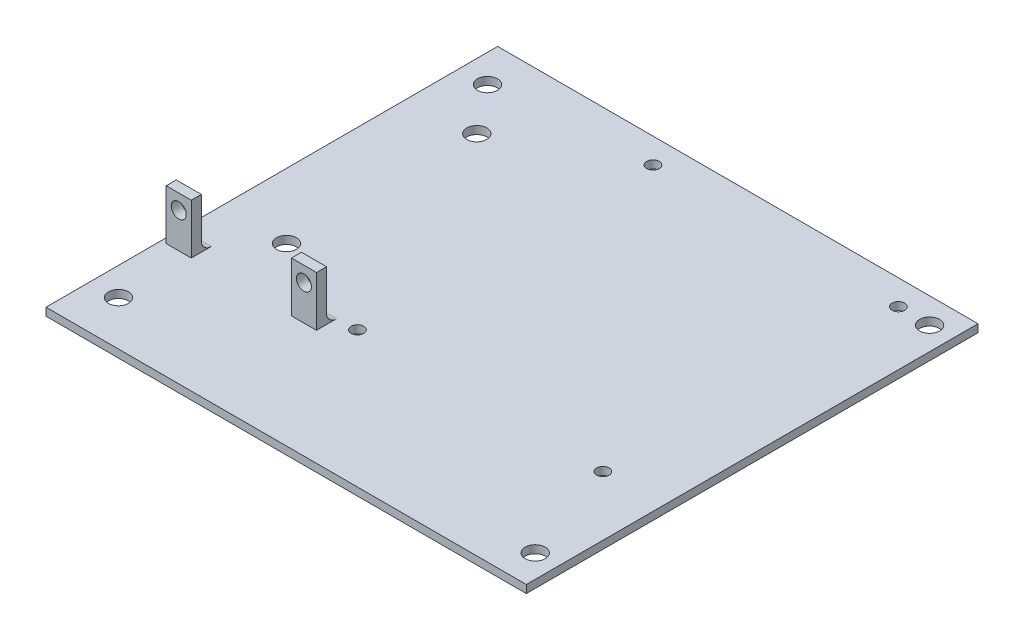
from build123d import *

# Parameters (mm, degrees)
SKETCH1_W               = 96.89
SKETCH1_H               = 90.17
PCB_DEPTH               = 1.57
SKETCH2_R               = 2
M3_MOUNTING_HOLES_DEPTH = 1.57
SKETCH5_W               = 0.5
SKETCH5_H               = 90.17
CUT_EXTRUDE1_DEPTH      = 2.57
SKETCH8_R               = 1.25
RPI_MOUNTING_HOLE_DEPTH = 10
SKETCH9_R               = 2
POWERADAPTERHOLES_DEPTH = 10
SKETCH10_W              = 5
SKETCH10_H              = 2
DSUB_HOLDER_DEPTH       = 10
FILLET2_R               = 2
DSUB_FIELDS_REACH       = 69.17
SKETCH11_R              = 1.5


with BuildPart() as part:
    # Sketch1 → PCB (new body)
    with BuildSketch(Plane(origin=(0, 0, 0), x_dir=(1, 0, 0), z_dir=(0, 1, 0))):
        with Locations((16.200949951, 63.633996534)):
            Rectangle(SKETCH1_W, SKETCH1_H)
    extrude(amount=PCB_DEPTH)

    # Sketch2 → M3 Mounting Holes (cut)
    with BuildSketch(Plane(origin=(0, 1.57, 0), x_dir=(1, 0, 0), z_dir=(0, 1, 0))):
        with Locations((59.565949951, 24.898996534)):
            Circle(SKETCH2_R)
        with Locations((-26.164050049, 27.438996534)):
            Circle(SKETCH2_R)
        with Locations((-26.164050049, 101.098996534)):
            Circle(SKETCH2_R)
        with Locations((59.565949951, 103.638996534)):
            Circle(SKETCH2_R)
    extrude(amount=-M3_MOUNTING_HOLES_DEPTH, mode=Mode.SUBTRACT)

    # Sketch5 → Cut-Extrude1 (cut, through all)
    with BuildSketch(Plane(origin=(0, 1.57, 0), x_dir=(1, 0, 0), z_dir=(0, 1, 0))):
        with Locations((-31.994050049, 63.633996534)):
            Rectangle(SKETCH5_W, SKETCH5_H)
        with Locations((64.395949951, 63.633996534)):
            Rectangle(SKETCH5_W, SKETCH5_H)
    extrude(amount=-CUT_EXTRUDE1_DEPTH, mode=Mode.SUBTRACT)

    # Sketch8 → RPi mounting hole (cut)
    with BuildSketch(Plane(origin=(0, 1.57, 0), x_dir=(1, 0, 0), z_dir=(0, 1, 0))):
        with Locations((3.255949951, 45.718996534)):
            Circle(SKETCH8_R)
        with Locations((52.255949951, 45.718996534)):
            Circle(SKETCH8_R)
        with Locations((4.255949951, 103.718996534)):
            Circle(SKETCH8_R)
        with Locations((53.255949951, 103.718996534)):
            Circle(SKETCH8_R)
    extrude(amount=-RPI_MOUNTING_HOLE_DEPTH, mode=Mode.SUBTRACT)

    # Sketch9 → PowerAdapterHoles (cut)
    with BuildSketch(Plane(origin=(0, 1.57, 0), x_dir=(1, 0, 0), z_dir=(0, 1, 0))):
        with Locations((-18.744050049, 91.548996534)):
            Circle(SKETCH9_R)
        with Locations((-18.744050049, 53.548996534)):
            Circle(SKETCH9_R)
    extrude(amount=-POWERADAPTERHOLES_DEPTH, mode=Mode.SUBTRACT)

    # Sketch10 → DSub Holder (add)
    with BuildSketch(Plane(origin=(0, 1.57, 0), x_dir=(1, 0, 0), z_dir=(0, 1, 0))):
        with Locations((-28.244050049, 42.548996534)):
            Rectangle(SKETCH10_W, SKETCH10_H)
        with Locations((-3.244050049, 42.548996534)):
            Rectangle(SKETCH10_W, SKETCH10_H)
    extrude(amount=DSUB_HOLDER_DEPTH)

    # Fillet2
    fillet2_edges = [part.edges().sort_by_distance(p)[0] for p in [
        (-3.244050049, 1.57, -43.548996534),
        (-28.244050049, 1.57, -43.548996534),
    ]]
    fillet(fillet2_edges, radius=FILLET2_R)

    # Sketch11 → DSub Fields (cut, up to next)
    with BuildSketch(Plane.XY.offset(-41.548996534), mode=Mode.PRIVATE) as dsub_fields_sk1:
        with Locations((-28.244050049, 8.57)):
            Circle(SKETCH11_R)
    dsub_fields_tool1 = extrude(dsub_fields_sk1.sketch, amount=-DSUB_FIELDS_REACH, mode=Mode.PRIVATE) & part.part
    add(dsub_fields_tool1.solids().sort_by_distance((-28.24405, 8.57, -41.548997))[0], mode=Mode.SUBTRACT)
    # Sketch11 → DSub Fields (cut, up to next)
    with BuildSketch(Plane.XY.offset(-41.548996534), mode=Mode.PRIVATE) as dsub_fields_sk2:
        with Locations((-3.254050049, 8.57)):
            Circle(SKETCH11_R)
    dsub_fields_tool2 = extrude(dsub_fields_sk2.sketch, amount=-DSUB_FIELDS_REACH, mode=Mode.PRIVATE) & part.part
    add(dsub_fields_tool2.solids().sort_by_distance((-3.25405, 8.57, -41.548997))[0], mode=Mode.SUBTRACT)


solid = part.part
